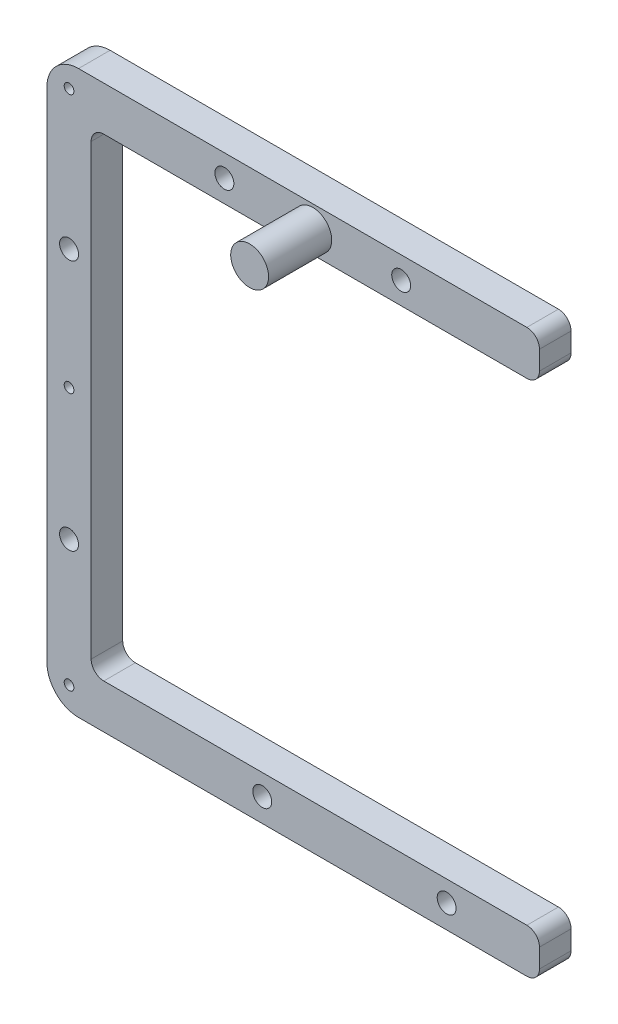
from build123d import *

# Parameters (mm, degrees)
BOSS_EXTRUDE1_DEPTH = 5
SKETCH2_R           = 3
BOSS_EXTRUDE2_DEPTH = 10
SKETCH3_R           = 1.5
CUT_EXTRUDE1_DEPTH  = 6
SKETCH4_R           = 0.77
CUT_EXTRUDE2_DEPTH  = 3


with BuildPart() as part:
    # Sketch1 → Boss-Extrude1 (new body)
    with BuildSketch(Plane.XY):
        with BuildLine():
            Line((0, 35.5), (0, -35.5))
            ThreePointArc((0, -35.5), (0.585786438, -36.914213562), (2, -37.5))
            Line((2, -37.5), (69, -37.5))
            ThreePointArc((69, -37.5), (70.414213562, -38.085786438), (71, -39.5))
            Line((71, -39.5), (71, -42.5))
            ThreePointArc((71, -42.5), (70.414213562, -43.914213562), (69, -44.5))
            Line((69, -44.5), (-2, -44.5))
            ThreePointArc((-2, -44.5), (-5.535533906, -43.035533906), (-7, -39.5))
            Line((-7, -39.5), (-7, 39.5))
            ThreePointArc((-7, 39.5), (-5.535533906, 43.035533906), (-2, 44.5))
            Line((-2, 44.5), (69, 44.5))
            ThreePointArc((69, 44.5), (70.414213562, 43.914213562), (71, 42.5))
            Line((71, 42.5), (71, 39.5))
            ThreePointArc((71, 39.5), (70.414213562, 38.085786438), (69, 37.5))
            Line((69, 37.5), (2, 37.5))
            ThreePointArc((2, 37.5), (0.585786438, 36.914213562), (0, 35.5))
        make_face()
    extrude(amount=BOSS_EXTRUDE1_DEPTH)

    # Sketch2 → Boss-Extrude2 (add)
    with BuildSketch(Plane.XY.offset(5)):
        with Locations((35.1, 41)):
            Circle(SKETCH2_R)
    extrude(amount=BOSS_EXTRUDE2_DEPTH)

    # Sketch3 → Cut-Extrude1 (cut, through all)
    with BuildSketch(Plane.XY.offset(5)):
        with Locations((49.1, 41)):
            Circle(SKETCH3_R)
        with Locations((21.1, 41)):
            Circle(SKETCH3_R)
        with Locations((-3.5, 19)):
            Circle(SKETCH3_R)
        with Locations((-3.5, -20.8)):
            Circle(SKETCH3_R)
        with Locations((27.1, -40.8)):
            Circle(SKETCH3_R)
        with Locations((56.3, -40.8)):
            Circle(SKETCH3_R)
    extrude(amount=-CUT_EXTRUDE1_DEPTH, mode=Mode.SUBTRACT)

    # Sketch4 → Cut-Extrude2 (cut)
    with BuildSketch(Plane.XY.offset(5)):
        with Locations((-3.5, 0)):
            Circle(SKETCH4_R)
        with Locations((-3.5, 41)):
            Circle(SKETCH4_R)
        with Locations((-3.5, -40.8)):
            Circle(SKETCH4_R)
    extrude(amount=-CUT_EXTRUDE2_DEPTH, mode=Mode.SUBTRACT)


solid = part.part
